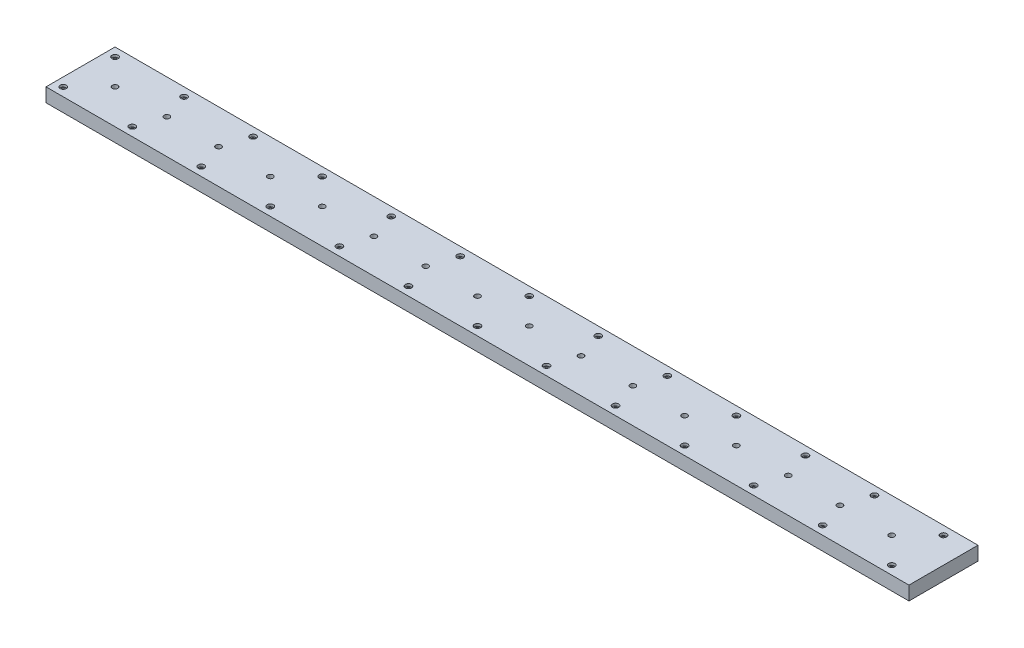
from build123d import *

# Parameters (mm, degrees)
ESBO_O1_W                                            = 2500
ESBO_O1_H                                            = 200
RESSALTO_EXTRUS_O1_DEPTH                             = 40
REBAIXO_PARA_PARAFUSO_ALLEN_SEXTAVADO_DE_D           = 11
REBAIXO_PARA_PARAFUSO_ALLEN_SEXTAVADO_DE_DEPTH       = 40
REBAIXO_PARA_PARAFUSO_ALLEN_SEXTAVADO_DE_CBORE_D     = 18
REBAIXO_PARA_PARAFUSO_ALLEN_SEXTAVADO_DE_CBORE_DEPTH = 7.1
FURO_ROSCADO_DE_M18X2_0_D                            = 16
FURO_ROSCADO_DE_M18X2_0_DEPTH                        = 40


with BuildPart() as part:
    # Esboço1 → Ressalto-extrusão1 (new body)
    with BuildSketch(Plane(origin=(0, 0, 0), x_dir=(1, 0, 0), z_dir=(0, 1, 0))):
        Rectangle(ESBO_O1_W, ESBO_O1_H)
    extrude(amount=RESSALTO_EXTRUS_O1_DEPTH)

    # Rebaixo para parafuso Allen sextavado de M101
    with Locations(Plane(origin=(0, 40, 0), x_dir=(1, 0, 0), z_dir=(0, 1, 0))):
        with Locations((-1225, 75), (-1025, 75), (-825, 75), (-625, 75), (-425, 75), (-225, 75), (-25, 75), (175, 75), (375, 75), (575, 75), (-1025, -75), (-825, -75), (-625, -75), (-425, -75), (-225, -75), (-25, -75), (175, -75), (375, -75), (575, -75), (-1225, -75), (775, 75), (775, -75), (975, 75), (1175, 75), (975, -75), (1175, -75)):
            CounterBoreHole(REBAIXO_PARA_PARAFUSO_ALLEN_SEXTAVADO_DE_D / 2, REBAIXO_PARA_PARAFUSO_ALLEN_SEXTAVADO_DE_CBORE_D / 2, REBAIXO_PARA_PARAFUSO_ALLEN_SEXTAVADO_DE_CBORE_DEPTH, depth=REBAIXO_PARA_PARAFUSO_ALLEN_SEXTAVADO_DE_DEPTH)

    # Furo roscado de M18x2.0
    with Locations(Plane(origin=(0, 40, 0), x_dir=(1, 0, 0), z_dir=(0, 1, 0))):
        with Locations((-1150, 0), (-1000, 0), (-850, 0), (-700, 0), (-550, 0), (-400, 0), (-250, 0), (-100, 0), (50, 0), (200, 0), (350, 0), (500, 0), (650, 0), (800, 0), (950, 0), (1100, 0)):
            Hole(FURO_ROSCADO_DE_M18X2_0_D / 2, depth=FURO_ROSCADO_DE_M18X2_0_DEPTH)


solid = part.part
